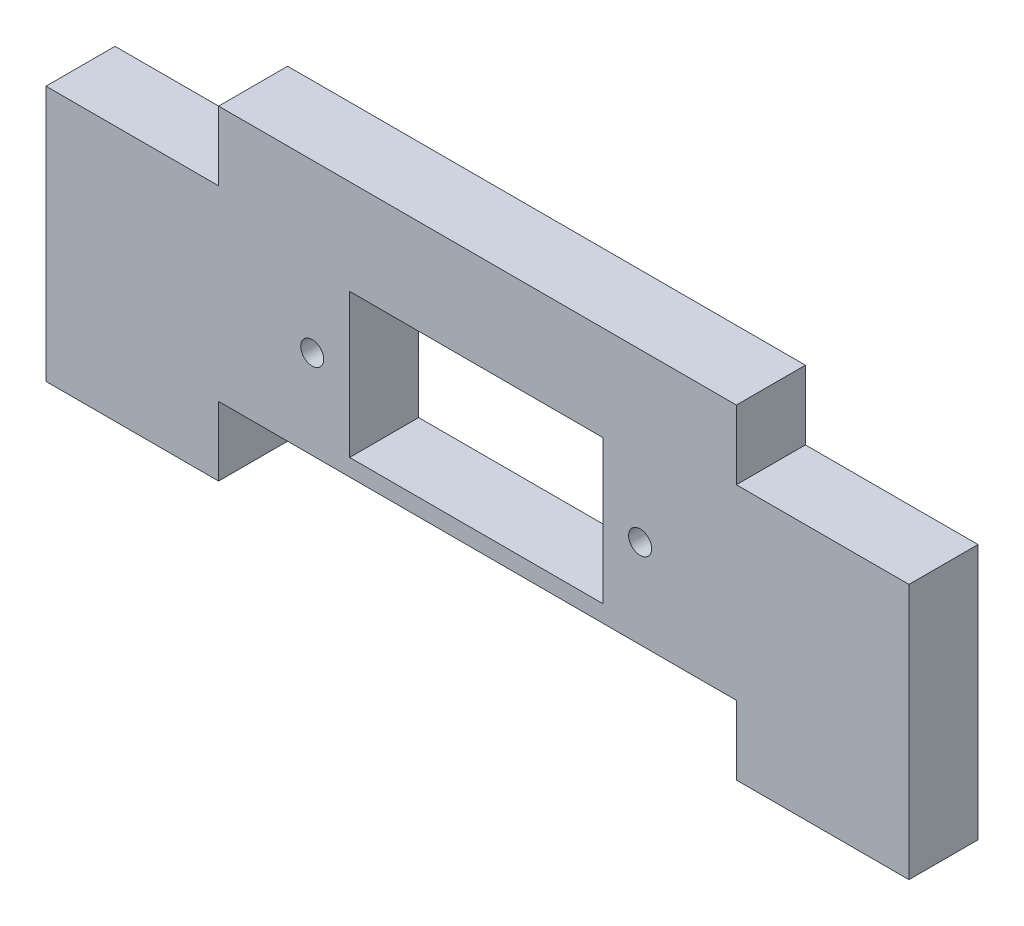
from build123d import *

# Parameters (mm, degrees)
SKETCH1_W                    = 44
SKETCH1_H                    = 25
BOSS_EXTRUDE1_DEPTH          = 12
F_4_0_4_DIAMETER_HOLE1_D     = 4
F_4_0_4_DIAMETER_HOLE1_DEPTH = 25
F_4_0_4_DIAMETER_HOLE1_TIP   = 1.201721238


with BuildPart() as part:
    # Sketch1 → Boss-Extrude1 (new body)
    with BuildSketch(Plane.XY.offset(232.248004761)):
        Polygon((-82.257473883, 114.914823413), (-82.257473883, 82.464823413), (-82.257473883, 70.464823413), (-52.257473883, 70.464823413), (-52.257473883, 82.464823413), (-29.482473883, 82.464823413), (14.967526117, 82.464823413), (37.742526117, 82.464823413), (37.742526117, 70.464823413), (67.742526117, 70.464823413), (67.742526117, 82.464823413), (67.742526117, 114.914823413), (37.742526117, 114.914823413), (37.742526117, 126.914823413), (-52.257473883, 126.914823413), (-52.257473883, 114.914823413), align=None)
        with Locations((-7.482473883, 97.914823413)):
            Rectangle(SKETCH1_W, SKETCH1_H, mode=Mode.SUBTRACT)
    extrude(amount=-BOSS_EXTRUDE1_DEPTH)

    # Ø4.0 (4) Diameter Hole1
    with Locations(Plane(origin=(-7.257473883, 0, 220.248004761), x_dir=(-1, 0, 0), z_dir=(0, 0, -1))):
        with Locations((-28.275, 97.914823413), (28.725, 97.914823413)):
            Hole(F_4_0_4_DIAMETER_HOLE1_D / 2, depth=F_4_0_4_DIAMETER_HOLE1_DEPTH)
            with Locations((0, 0, -(F_4_0_4_DIAMETER_HOLE1_DEPTH + F_4_0_4_DIAMETER_HOLE1_TIP / 2))):  # 118° drill point
                Cone(0, F_4_0_4_DIAMETER_HOLE1_D / 2, F_4_0_4_DIAMETER_HOLE1_TIP, mode=Mode.SUBTRACT)


solid = part.part
